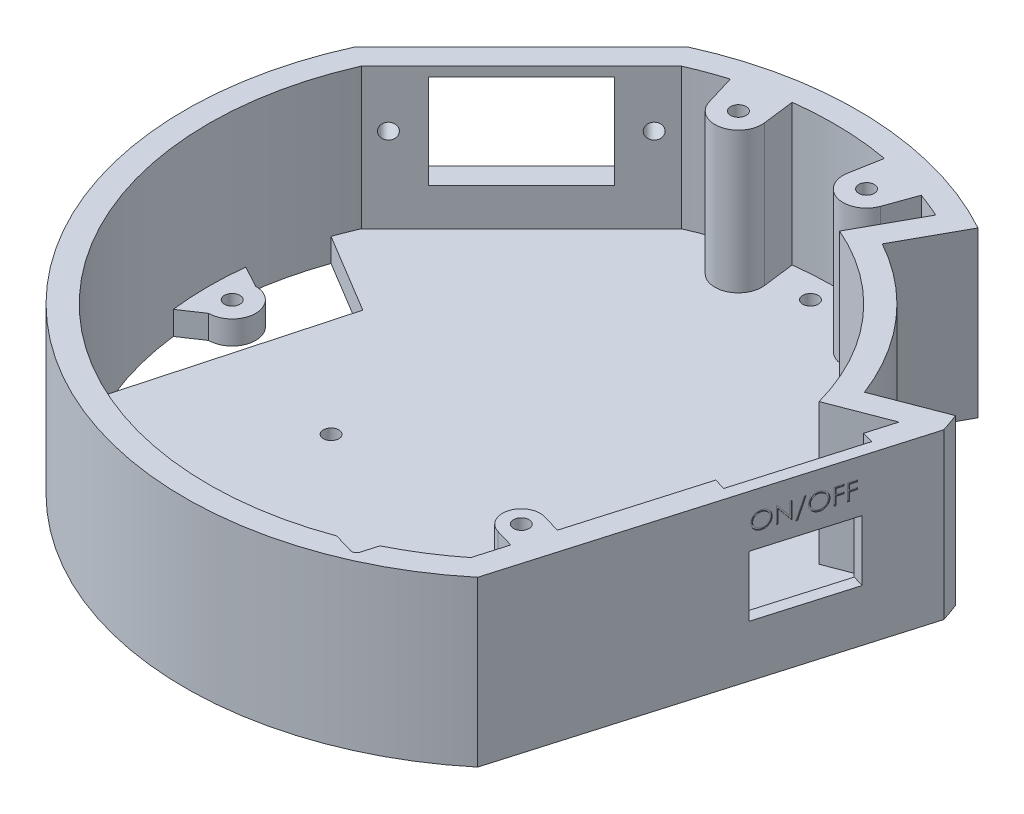
from build123d import *

# Parameters (mm, degrees)
BOSS_EXTRUDE1_DEPTH = 5
SKETCH2_R           = 1.65
CUT_EXTRUDE1_DEPTH  = 6
BOSS_EXTRUDE3_DEPTH = 30
CUT_EXTRUDE2_DEPTH  = 15
FILLET1_R           = 1
SKETCH5_R           = 1.65
CUT_EXTRUDE3_DEPTH  = 6
SKETCH6_R           = 1.65
SKETCH6_W           = 28
SKETCH6_H           = 20
CUT_EXTRUDE4_DEPTH  = 102.17990932
SKETCH7_W           = 19.4
SKETCH7_H           = 12.9
CUT_EXTRUDE5_DEPTH  = 5
CUT_EXTRUDE6_START  = -2.5
SKETCH8_W           = 25.4
SKETCH8_H           = 30
CUT_EXTRUDE6_DEPTH  = 5
CUT_EXTRUDE7_DEPTH  = 0.2
CUT_EXTRUDE8_DEPTH  = 6
SKETCH11_R          = 1.65
BOSS_EXTRUDE4_DEPTH = 35
CUT_EXTRUDE9_START  = -3
CUT_EXTRUDE9_DEPTH  = 2.6


with BuildPart() as part:
    # Sketch1 → Boss-Extrude1 (new body)
    with BuildSketch(Plane(origin=(0, 0, 0), x_dir=(1, 0, 0), z_dir=(0, 1, 0))):
        with BuildLine():
            Line((45.736375855, -55.017005995), (68.149505263, 21.779163377))
            ThreePointArc((68.149505263, 21.779163377), (67.498860282, 23.71899841), (66.793011614, 25.63943495))
            Line((66.793011614, 25.63943495), (52.789305216, 20.263915707))
            ThreePointArc((52.789305216, 20.263915707), (42.645904251, 37.130363258), (27.335841873, 49.498371429))
            Line((27.335841873, 49.498371429), (34.587369472, 62.629073903))
            ThreePointArc((34.587369472, 62.629073903), (2.723048346, 71.493160741), (-29.723211396, 65.078550455))
            Line((-29.723211396, 65.078550455), (-65.078550455, 29.723211396))
            ThreePointArc((-65.078550455, 29.723211396), (-43.459820989, -56.832481774), (45.736375855, -55.017005995))
        make_face()
    extrude(amount=BOSS_EXTRUDE1_DEPTH)

    # Sketch2 → Cut-Extrude1 (cut, through all)
    with BuildSketch(Plane(origin=(0, 5, 0), x_dir=(1, 0, 0), z_dir=(0, 1, 0))):
        with Locations((0, 61.55)):
            Circle(SKETCH2_R)
        with Locations((-43.522422382, -43.522422382)):
            Circle(SKETCH2_R)
        with Locations((-61.55, 0)):
            Circle(SKETCH2_R)
        with Locations((3.221278107, -61.465647864)):
            Circle(SKETCH2_R)
    extrude(amount=-CUT_EXTRUDE1_DEPTH, mode=Mode.SUBTRACT)

    # Sketch3 → Boss-Extrude3 (add)
    with BuildSketch(Plane(origin=(0, 5, 0), x_dir=(1, 0, 0), z_dir=(0, 1, 0))):
        with BuildLine():
            Line((34.587369472, 62.629073903), (27.335841873, 49.498371429))
            ThreePointArc((27.335841873, 49.498371429), (42.645904251, 37.130363258), (52.789305216, 20.263915707))
            Line((52.789305216, 20.263915707), (66.793011614, 25.63943495))
            ThreePointArc((66.793011614, 25.63943495), (67.498860282, 23.71899841), (68.149505263, 21.779163377))
            Line((68.149505263, 21.779163377), (45.736375855, -55.017005995))
            ThreePointArc((45.736375855, -55.017005995), (-43.459820989, -56.832481774), (-65.078550455, 29.723211396))
            Line((-65.078550455, 29.723211396), (-29.723211396, 65.078550455))
            ThreePointArc((-29.723211396, 65.078550455), (2.723048346, 71.493160741), (34.587369472, 62.629073903))
        make_face()
        with BuildLine():
            Line((41.373300987, -52.119928918), (61.963390881, 18.42979228))
            Line((61.963390881, 18.42979228), (49.686308368, 13.717061848))
            ThreePointArc((49.686308368, 13.717061848), (38.874933851, 33.847105387), (20.424251898, 47.32585931))
            Line((20.424251898, 47.32585931), (27.702354426, 60.504682333))
            ThreePointArc((27.702354426, 60.504682333), (0.474099558, 66.543311118), (-26.837433367, 60.893260672))
            Line((-26.837433367, 60.893260672), (-60.893260672, 26.837433367))
            ThreePointArc((-60.893260672, 26.837433367), (-40.667228468, -52.672702168), (41.373300987, -52.119928918))
        make_face(mode=Mode.SUBTRACT)
    extrude(amount=BOSS_EXTRUDE3_DEPTH)

    # Sketch4 → Cut-Extrude2 (cut)
    with BuildSketch(Plane(origin=(-10.769878987, 0, 36.901828197), x_dir=(0, -1, 0), z_dir=(0.280164118, 0, -0.959952117))):
        with BuildLine():
            Line((-19, -45.06852177), (-35, -45.06852177))
            ThreePointArc((-35, -45.06852177), (-38.5, -41.56852177), (-35, -38.06852177))
            Line((-35, -38.06852177), (-19, -38.06852177))
            ThreePointArc((-19, -38.06852177), (-15.5, -41.56852177), (-19, -45.06852177))
        make_face()
    extrude(amount=-CUT_EXTRUDE2_DEPTH, mode=Mode.SUBTRACT)

    # Fillet1
    fillet1_edges = [part.edges().sort_by_distance(p)[0] for p in [
        (26.529321315, 15.921147738, 63.413460481),
        (28.291282139, 27, 63.927692588),
    ]]
    fillet(fillet1_edges, radius=FILLET1_R)

    # Sketch5 → Cut-Extrude3 (cut, through all)
    with BuildSketch(Plane(origin=(0, 5, 0), x_dir=(1, 0, 0), z_dir=(0, 1, 0))):
        with Locations((26.569138232, -29.673397669)):
            Circle(SKETCH5_R)
        with Locations((-26.228228211, -14.264371202)):
            Circle(SKETCH5_R)
    extrude(amount=-CUT_EXTRUDE3_DEPTH, mode=Mode.SUBTRACT)

    # Sketch6 → Cut-Extrude4 (cut, through all)
    with BuildSketch(Plane(origin=(0, 0, 0), x_dir=(0.707106781, 0, -0.707106781), z_dir=(0.707106781, 0, 0.707106781))):
        with Locations((20, 23)):
            Circle(SKETCH6_R)
        with Locations((-20, 23)):
            Circle(SKETCH6_R)
        with Locations((0, 23)):
            Rectangle(SKETCH6_W, SKETCH6_H)
    extrude(amount=-CUT_EXTRUDE4_DEPTH, mode=Mode.SUBTRACT)

    # Sketch7 → Cut-Extrude5 (cut)
    with BuildSketch(Plane(origin=(56.942940559, 0, 16.618921309), x_dir=(0.280164118, 0, -0.959952117), z_dir=(0.959952117, 0, 0.280164118))):
        with Locations((16.3, 17.5)):
            Rectangle(SKETCH7_W, SKETCH7_H)
    extrude(amount=-CUT_EXTRUDE5_DEPTH, mode=Mode.SUBTRACT)

    # Sketch8 → Cut-Extrude6 (cut)
    with BuildSketch(Plane(origin=(56.942940559, 0, 16.618921309), x_dir=(0.280164118, 0, -0.959952117), z_dir=(0.959952117, 0, 0.280164118)).offset(CUT_EXTRUDE6_START)):
        with Locations((16.3, 20)):
            Rectangle(SKETCH8_W, SKETCH8_H)
    extrude(amount=-CUT_EXTRUDE6_DEPTH, mode=Mode.SUBTRACT)

    # Sketch9 → Cut-Extrude7 (cut)
    with BuildSketch(Plane(origin=(56.942940559, 0, 16.618921309), x_dir=(0.280164118, 0, -0.959952117), z_dir=(0.959952117, 0, 0.280164118))):
        with BuildLine():
            add(Edge.make_bspline(
                [(8.682970513, 30.909861948), (8.747778619, 30.908220468), (8.875067086, 30.904996468), (9.062141983, 30.880317364), (9.240737079, 30.837621974), (9.412307218, 30.780758992), (9.574800194, 30.704904606), (9.729439087, 30.613219458), (9.87585596, 30.504742999), (10.012077342, 30.380313772), (10.136734292, 30.244930318), (10.246560179, 30.100452408), (10.338602472, 29.947753606), (10.414188259, 29.787292775), (10.473486869, 29.619432807), (10.514405913, 29.443278805), (10.540544063, 29.259972114), (10.54359984, 29.13494525), (10.54515, 29.071520602)],
                knots=[0, 0, 0, 0, 0.000194393, 0.000381804, 0.00056479, 0.000744601, 0.000923091, 0.001101652, 0.001283106, 0.001468738, 0.001654324, 0.001834514, 0.002012231, 0.002188181, 0.002365797, 0.002545211, 0.002729936, 0.002920126, 0.002920126, 0.002920126, 0.002920126], degree=3))
            add(Edge.make_bspline(
                [(10.54515, 29.071520602), (10.543600068, 29.008563155), (10.540544971, 28.884466735), (10.514376193, 28.702323291), (10.473335193, 28.527232594), (10.414738927, 28.359486941), (10.339513449, 28.198909378), (10.246858278, 28.045922424), (10.137717067, 27.900475925), (10.013510216, 27.76416326), (9.878109174, 27.63916579), (9.732878907, 27.530246914), (9.581085587, 27.436522789), (9.420775879, 27.361739115), (9.254075842, 27.301967195), (9.079493519, 27.261214565), (8.897846965, 27.234927522), (8.773975961, 27.231909006), (8.711015385, 27.230374768)],
                knots=[0, 0, 0, 0, 0.000188789, 0.000372126, 0.000550857, 0.00072758, 0.000904164, 0.001081881, 0.001263191, 0.001448823, 0.00163441, 0.001815159, 0.001992641, 0.002168591, 0.002344885, 0.002522934, 0.002705576, 0.002894365, 0.002894365, 0.002894365, 0.002894365], degree=3))
            add(Edge.make_bspline(
                [(8.711015385, 27.230374768), (8.647591066, 27.231924155), (8.52256485, 27.234978409), (8.339027814, 27.261159814), (8.162750071, 27.302101118), (7.994235719, 27.360610554), (7.83339079, 27.436227785), (7.679900707, 27.528432164), (7.53438156, 27.637839305), (7.398039813, 27.762005879), (7.273290615, 27.897177432), (7.164531239, 28.042011687), (7.072306126, 28.193667143), (6.996942794, 28.352564667), (6.937278334, 28.51793611), (6.896573516, 28.690884588), (6.870237564, 28.870424093), (6.867202718, 28.992666992), (6.865662821, 29.054693679)],
                knots=[0, 0, 0, 0, 0.00019019, 0.000374915, 0.000555011, 0.000732396, 0.00090898, 0.001087298, 0.001268608, 0.00145424, 0.001639827, 0.001819595, 0.001996712, 0.002171394, 0.002346367, 0.002523053, 0.002703612, 0.002889599, 0.002889599, 0.002889599, 0.002889599], degree=3))
            add(Edge.make_bspline(
                [(6.865662821, 29.054693679), (6.866197456, 29.096326348), (6.867259982, 29.179066471), (6.880051675, 29.301933071), (6.898613376, 29.422823729), (6.925215289, 29.541394677), (6.960006956, 29.657355662), (7.001058983, 29.771506425), (7.051198828, 29.882690148), (7.107879476, 29.99143354), (7.171141284, 30.096041446), (7.241017034, 30.194921029), (7.315052402, 30.288902026), (7.396215796, 30.37554903), (7.481832241, 30.457382686), (7.573290619, 30.533145403), (7.670032864, 30.603520354), (7.772475243, 30.666940695), (7.878093518, 30.72429983), (7.986970296, 30.773521681), (8.097626868, 30.815767742), (8.210581516, 30.850008567), (8.325534288, 30.877040603), (8.442736072, 30.895447957), (8.562093498, 30.908272275), (8.642504817, 30.909329777), (8.682970513, 30.909861948)],
                knots=[0, 0, 0, 0, 0.000124849, 0.000248123, 0.000370193, 0.00049164, 0.000612319, 0.000733199, 0.000855287, 0.000977905, 0.001100913, 0.001221706, 0.001340948, 0.001459521, 0.001577551, 0.001696047, 0.001815534, 0.001936153, 0.002057243, 0.002175846, 0.002294342, 0.002412335, 0.002529682, 0.00264829, 0.002768075, 0.00288942, 0.00288942, 0.00288942, 0.00288942], degree=3))
        make_face()
        with BuildLine():
            add(Edge.make_bspline(
                [(8.698395192, 30.550887589), (8.665180559, 30.550482699), (8.599068826, 30.549676789), (8.50078429, 30.539061073), (8.403792356, 30.523931184), (8.308072994, 30.502349664), (8.214026704, 30.472945611), (8.120776863, 30.439104703), (8.029173809, 30.397883612), (7.939519951, 30.351310908), (7.852604876, 30.299761987), (7.770592175, 30.24279022), (7.693269531, 30.181731666), (7.620826264, 30.116443828), (7.553475092, 30.046594226), (7.489890391, 29.97324179), (7.432620809, 29.894289899), (7.380135232, 29.811879492), (7.333167392, 29.726117911), (7.291402037, 29.637908049), (7.257238028, 29.546530362), (7.229375652, 29.452976205), (7.206275841, 29.357393745), (7.191641917, 29.259057896), (7.180909558, 29.158462784), (7.180149712, 29.09048093), (7.179765385, 29.056095922)],
                knots=[0, 0, 0, 0, 9.9599e-05, 0.000198245, 0.000296222, 0.00039402, 0.00049227, 0.000591646, 0.000691452, 0.000793368, 0.000894612, 0.000994383, 0.001092713, 0.00119001, 0.001286696, 0.001383657, 0.001480979, 0.001579008, 0.001676595, 0.001774142, 0.001871547, 0.001968922, 0.002066879, 0.00216624, 0.00226698, 0.002370083, 0.002370083, 0.002370083, 0.002370083], degree=3))
            add(Edge.make_bspline(
                [(7.179765385, 29.056095922), (7.181040247, 29.005533701), (7.183548295, 28.906062171), (7.205505865, 28.760294027), (7.239327839, 28.620205741), (7.289185206, 28.486563832), (7.35153582, 28.358219549), (7.42856271, 28.236311444), (7.519821796, 28.12080657), (7.623485323, 28.012511301), (7.736808029, 27.913665497), (7.857140759, 27.826902088), (7.983194367, 27.753491838), (8.115297569, 27.693686766), (8.252745108, 27.646297028), (8.396422659, 27.613818397), (8.545373119, 27.592442941), (8.646903774, 27.590390185), (8.698395192, 27.589349127)],
                knots=[0, 0, 0, 0, 0.000151605, 0.000298253, 0.000441263, 0.000583229, 0.000725274, 0.000868635, 0.001014928, 0.001166177, 0.001317744, 0.00146543, 0.001610576, 0.001754594, 0.001899821, 0.002045914, 0.002195936, 0.002350312, 0.002350312, 0.002350312, 0.002350312], degree=3))
            add(Edge.make_bspline(
                [(8.698395192, 27.589349127), (8.733004694, 27.589824632), (8.80164573, 27.5907677), (8.903741253, 27.600266376), (9.003997464, 27.615498246), (9.102273744, 27.637428902), (9.198458556, 27.664876108), (9.292953359, 27.697483836), (9.384751649, 27.73816504), (9.475011487, 27.783112991), (9.561407729, 27.834353149), (9.643883261, 27.889391298), (9.720359241, 27.950359919), (9.792748312, 28.014677732), (9.860376001, 28.083641579), (9.922784985, 28.157161801), (9.979765118, 28.235702459), (10.032230764, 28.317987864), (10.079034027, 28.403984117), (10.119813126, 28.492513795), (10.154409242, 28.583358904), (10.182337747, 28.676650476), (10.204223208, 28.772211325), (10.219303128, 28.870169403), (10.229851567, 28.970328745), (10.230646644, 29.038072601), (10.231047436, 29.072221723)],
                knots=[0, 0, 0, 0, 0.000103804, 0.000205874, 0.000307314, 0.000407849, 0.000507719, 0.000607281, 0.000707445, 0.000808723, 0.000909609, 0.001008589, 0.001105934, 0.001202762, 0.001298946, 0.001395452, 0.001491794, 0.001589823, 0.001688026, 0.001785277, 0.001882027, 0.001979402, 0.0020772, 0.002175869, 0.002276609, 0.002379011, 0.002379011, 0.002379011, 0.002379011], degree=3))
            add(Edge.make_bspline(
                [(10.231047436, 29.072221723), (10.230646323, 29.106137228), (10.229850642, 29.173414878), (10.219308167, 29.272875696), (10.204207277, 29.370128908), (10.182444568, 29.464792711), (10.154394415, 29.556891236), (10.119807084, 29.646337984), (10.079021785, 29.733466179), (10.032213561, 29.818060476), (9.979597737, 29.899235214), (9.922103494, 29.976837626), (9.858738146, 30.049410367), (9.791312121, 30.118745061), (9.718141235, 30.183362951), (9.639556941, 30.243285472), (9.556513264, 30.299958746), (9.468586028, 30.351084308), (9.377842074, 30.398298541), (9.284728116, 30.438749544), (9.190299017, 30.473121663), (9.094794904, 30.502438628), (8.997411926, 30.523846658), (8.898808097, 30.539074708), (8.799119839, 30.549673094), (8.732076619, 30.550481473), (8.698395192, 30.550887589)],
                knots=[0, 0, 0, 0, 0.000101701, 0.000201743, 0.00029972, 0.000396835, 0.000492868, 0.000588308, 0.000684288, 0.000781261, 0.000878109, 0.000974304, 0.001070733, 0.001166917, 0.001264269, 0.001363274, 0.001463228, 0.001565678, 0.001668217, 0.001769947, 0.001869982, 0.001969573, 0.002069423, 0.002168785, 0.002268827, 0.002369827, 0.002369827, 0.002369827, 0.002369827], degree=3))
        make_face(mode=Mode.SUBTRACT)
        Polygon((11.263098718, 27.320118358), (11.263098718, 30.820118358), (11.329004167, 30.820118358), (13.641303846, 28.065410826), (13.641303846, 30.820118358), (13.95540641, 30.820118358), (13.95540641, 27.320118358), (13.883891987, 27.320118358), (11.577201282, 30.068515794), (11.577201282, 27.320118358), align=None)
        Polygon((16.378483333, 30.909861948), (14.914541026, 26.826528614), (14.583611539, 26.826528614), (16.047553846, 30.909861948), align=None)
        with BuildLine():
            add(Edge.make_bspline(
                [(18.59963718, 30.909861948), (18.664445285, 30.908220468), (18.791733752, 30.904996468), (18.97880865, 30.880317364), (19.157403745, 30.837621974), (19.328973884, 30.780758992), (19.491466861, 30.704904606), (19.646105753, 30.613219458), (19.792522627, 30.504742999), (19.928744009, 30.380313772), (20.053400959, 30.244930318), (20.163226845, 30.100452408), (20.255269139, 29.947753606), (20.330854926, 29.787292775), (20.390153536, 29.619432807), (20.431072579, 29.443278805), (20.45721073, 29.259972114), (20.460266507, 29.13494525), (20.461816667, 29.071520602)],
                knots=[0, 0, 0, 0, 0.000194393, 0.000381804, 0.00056479, 0.000744601, 0.000923091, 0.001101652, 0.001283106, 0.001468738, 0.001654324, 0.001834514, 0.002012231, 0.002188181, 0.002365797, 0.002545211, 0.002729936, 0.002920126, 0.002920126, 0.002920126, 0.002920126], degree=3))
            add(Edge.make_bspline(
                [(20.461816667, 29.071520602), (20.460266734, 29.008563155), (20.457211638, 28.884466735), (20.43104286, 28.702323291), (20.39000186, 28.527232594), (20.331405594, 28.359486941), (20.256180116, 28.198909378), (20.163524944, 28.045922424), (20.054383734, 27.900475925), (19.930176883, 27.76416326), (19.794775841, 27.63916579), (19.649545574, 27.530246914), (19.497752254, 27.436522789), (19.337442546, 27.361739115), (19.170742509, 27.301967195), (18.996160186, 27.261214565), (18.814513632, 27.234927522), (18.690642628, 27.231909006), (18.627682051, 27.230374768)],
                knots=[0, 0, 0, 0, 0.000188789, 0.000372126, 0.000550857, 0.00072758, 0.000904164, 0.001081881, 0.001263191, 0.001448823, 0.00163441, 0.001815159, 0.001992641, 0.002168591, 0.002344885, 0.002522934, 0.002705576, 0.002894365, 0.002894365, 0.002894365, 0.002894365], degree=3))
            add(Edge.make_bspline(
                [(18.627682051, 27.230374768), (18.564257732, 27.231924155), (18.439231516, 27.234978409), (18.255694481, 27.261159814), (18.079416737, 27.302101118), (17.910902386, 27.360610554), (17.750057456, 27.436227785), (17.596567374, 27.528432164), (17.451048226, 27.637839305), (17.31470648, 27.762005879), (17.189957282, 27.897177432), (17.081197906, 28.042011687), (16.988972793, 28.193667143), (16.91360946, 28.352564667), (16.853945001, 28.51793611), (16.813240183, 28.690884588), (16.786904231, 28.870424093), (16.783869384, 28.992666992), (16.782329487, 29.054693679)],
                knots=[0, 0, 0, 0, 0.00019019, 0.000374915, 0.000555011, 0.000732396, 0.00090898, 0.001087298, 0.001268608, 0.00145424, 0.001639827, 0.001819595, 0.001996712, 0.002171394, 0.002346367, 0.002523053, 0.002703612, 0.002889599, 0.002889599, 0.002889599, 0.002889599], degree=3))
            add(Edge.make_bspline(
                [(16.782329487, 29.054693679), (16.782864123, 29.096326348), (16.783926649, 29.179066471), (16.796718342, 29.301933071), (16.815280043, 29.422823729), (16.841881955, 29.541394677), (16.876673622, 29.657355662), (16.91772565, 29.771506425), (16.967865495, 29.882690148), (17.024546143, 29.99143354), (17.087807951, 30.096041446), (17.157683701, 30.194921029), (17.231719069, 30.288902026), (17.312882463, 30.37554903), (17.398498908, 30.457382686), (17.489957286, 30.533145403), (17.58669953, 30.603520354), (17.68914191, 30.666940695), (17.794760185, 30.72429983), (17.903636963, 30.773521681), (18.014293534, 30.815767742), (18.127248182, 30.850008567), (18.242200954, 30.877040603), (18.359402739, 30.895447957), (18.478760165, 30.908272275), (18.559171484, 30.909329777), (18.59963718, 30.909861948)],
                knots=[0, 0, 0, 0, 0.000124849, 0.000248123, 0.000370193, 0.00049164, 0.000612319, 0.000733199, 0.000855287, 0.000977905, 0.001100913, 0.001221706, 0.001340948, 0.001459521, 0.001577551, 0.001696047, 0.001815534, 0.001936153, 0.002057243, 0.002175846, 0.002294342, 0.002412335, 0.002529682, 0.00264829, 0.002768075, 0.00288942, 0.00288942, 0.00288942, 0.00288942], degree=3))
        make_face()
        with BuildLine():
            add(Edge.make_bspline(
                [(18.615061859, 30.550887589), (18.581847226, 30.550482699), (18.515735493, 30.549676789), (18.417450956, 30.539061073), (18.320459023, 30.523931184), (18.22473966, 30.502349664), (18.130693371, 30.472945611), (18.03744353, 30.439104703), (17.945840476, 30.397883612), (17.856186618, 30.351310908), (17.769271543, 30.299761987), (17.687258841, 30.24279022), (17.609936197, 30.181731666), (17.537492931, 30.116443828), (17.470141759, 30.046594226), (17.406557057, 29.97324179), (17.349287476, 29.894289899), (17.296801899, 29.811879492), (17.249834058, 29.726117911), (17.208068704, 29.637908049), (17.173904695, 29.546530362), (17.146042319, 29.452976205), (17.122942508, 29.357393745), (17.108308584, 29.259057896), (17.097576224, 29.158462784), (17.096816379, 29.09048093), (17.096432051, 29.056095922)],
                knots=[0, 0, 0, 0, 9.9599e-05, 0.000198245, 0.000296222, 0.00039402, 0.00049227, 0.000591646, 0.000691452, 0.000793368, 0.000894612, 0.000994383, 0.001092713, 0.00119001, 0.001286696, 0.001383657, 0.001480979, 0.001579008, 0.001676595, 0.001774142, 0.001871547, 0.001968922, 0.002066879, 0.00216624, 0.00226698, 0.002370083, 0.002370083, 0.002370083, 0.002370083], degree=3))
            add(Edge.make_bspline(
                [(17.096432051, 29.056095922), (17.097706913, 29.005533701), (17.100214961, 28.906062171), (17.122172531, 28.760294027), (17.155994506, 28.620205741), (17.205851872, 28.486563832), (17.268202487, 28.358219549), (17.345229377, 28.236311444), (17.436488463, 28.12080657), (17.540151989, 28.012511301), (17.653474696, 27.913665497), (17.773807426, 27.826902088), (17.899861033, 27.753491838), (18.031964236, 27.693686766), (18.169411775, 27.646297028), (18.313089326, 27.613818397), (18.462039786, 27.592442941), (18.563570441, 27.590390185), (18.615061859, 27.589349127)],
                knots=[0, 0, 0, 0, 0.000151605, 0.000298253, 0.000441263, 0.000583229, 0.000725274, 0.000868635, 0.001014928, 0.001166177, 0.001317744, 0.00146543, 0.001610576, 0.001754594, 0.001899821, 0.002045914, 0.002195936, 0.002350312, 0.002350312, 0.002350312, 0.002350312], degree=3))
            add(Edge.make_bspline(
                [(18.615061859, 27.589349127), (18.649671361, 27.589824632), (18.718312397, 27.5907677), (18.820407919, 27.600266376), (18.920664131, 27.615498246), (19.018940411, 27.637428902), (19.115125222, 27.664876108), (19.209620026, 27.697483836), (19.301418316, 27.73816504), (19.391678154, 27.783112991), (19.478074395, 27.834353149), (19.560549928, 27.889391298), (19.637025907, 27.950359919), (19.709414979, 28.014677732), (19.777042668, 28.083641579), (19.839451652, 28.157161801), (19.896431784, 28.235702459), (19.948897431, 28.317987864), (19.995700694, 28.403984117), (20.036479793, 28.492513795), (20.071075909, 28.583358904), (20.099004413, 28.676650476), (20.120889875, 28.772211325), (20.135969795, 28.870169403), (20.146518234, 28.970328745), (20.147313311, 29.038072601), (20.147714103, 29.072221723)],
                knots=[0, 0, 0, 0, 0.000103804, 0.000205874, 0.000307314, 0.000407849, 0.000507719, 0.000607281, 0.000707445, 0.000808723, 0.000909609, 0.001008589, 0.001105934, 0.001202762, 0.001298946, 0.001395452, 0.001491794, 0.001589823, 0.001688026, 0.001785277, 0.001882027, 0.001979402, 0.0020772, 0.002175869, 0.002276609, 0.002379011, 0.002379011, 0.002379011, 0.002379011], degree=3))
            add(Edge.make_bspline(
                [(20.147714103, 29.072221723), (20.14731299, 29.106137228), (20.146517308, 29.173414878), (20.135974834, 29.272875696), (20.120873943, 29.370128908), (20.099111235, 29.464792711), (20.071061081, 29.556891236), (20.036473751, 29.646337984), (19.995688452, 29.733466179), (19.948880227, 29.818060476), (19.896264404, 29.899235214), (19.83877016, 29.976837626), (19.775404812, 30.049410367), (19.707978787, 30.118745061), (19.634807902, 30.183362951), (19.556223608, 30.243285472), (19.47317993, 30.299958746), (19.385252695, 30.351084308), (19.294508741, 30.398298541), (19.201394783, 30.438749544), (19.106965683, 30.473121663), (19.011461571, 30.502438628), (18.914078593, 30.523846658), (18.815474764, 30.539074708), (18.715786505, 30.549673094), (18.648743286, 30.550481473), (18.615061859, 30.550887589)],
                knots=[0, 0, 0, 0, 0.000101701, 0.000201743, 0.00029972, 0.000396835, 0.000492868, 0.000588308, 0.000684288, 0.000781261, 0.000878109, 0.000974304, 0.001070733, 0.001166917, 0.001264269, 0.001363274, 0.001463228, 0.001565678, 0.001668217, 0.001769947, 0.001869982, 0.001969573, 0.002069423, 0.002168785, 0.002268827, 0.002369827, 0.002369827, 0.002369827, 0.002369827], degree=3))
        make_face(mode=Mode.SUBTRACT)
        Polygon((21.179765385, 30.820118358), (22.88489359, 30.820118358), (22.88489359, 30.461143999), (21.493867949, 30.461143999), (21.493867949, 29.384220922), (22.88489359, 29.384220922), (22.88489359, 29.025246563), (21.493867949, 29.025246563), (21.493867949, 27.320118358), (21.179765385, 27.320118358), align=None)
        Polygon((23.513098718, 30.820118358), (25.218226923, 30.820118358), (25.218226923, 30.461143999), (23.827201282, 30.461143999), (23.827201282, 29.384220922), (25.218226923, 29.384220922), (25.218226923, 29.025246563), (23.827201282, 29.025246563), (23.827201282, 27.320118358), (23.513098718, 27.320118358), align=None)
    extrude(amount=-CUT_EXTRUDE7_DEPTH, mode=Mode.SUBTRACT)

    # Sketch10 → Cut-Extrude8 (cut)
    with BuildSketch(Plane(origin=(0, 0, 0), x_dir=(1, 0, 0), z_dir=(0, 1, 0))):
        with BuildLine():
            Line((-61.55, -5), (-66.059328559, -8.025094099))
            ThreePointArc((-66.059328559, -8.025094099), (-63.224651437, -20.75766065), (-57.960586534, -32.692620477))
            Line((-57.960586534, -32.692620477), (-45.744307294, 12.001168416))
            Line((-45.744307294, 12.001168416), (-62.726398584, 22.217919473))
            ThreePointArc((-62.726398584, 22.217919473), (-64.844935264, 14.945614596), (-66.123306155, 7.479666314))
            Line((-66.123306155, 7.479666314), (-61.55, 5))
            ThreePointArc((-61.55, 5), (-56.55, 0), (-61.55, -5))
        make_face()
    extrude(amount=CUT_EXTRUDE8_DEPTH, mode=Mode.SUBTRACT)

    # Sketch11 → Boss-Extrude4 (add)
    with BuildSketch(Plane(origin=(0, 0, 0), x_dir=(1, 0, 0), z_dir=(0, 1, 0))):
        with BuildLine():
            Line((20.234131808, 56.263486472), (22.519667869, 62.618699955))
            ThreePointArc((22.519667869, 62.618699955), (17.223113356, 64.27753411), (11.806745518, 65.489218848))
            Line((11.806745518, 65.489218848), (10.608471067, 58.842674494))
            ThreePointArc((10.608471067, 58.842674494), (14.235047481, 53.125920446), (20.234131808, 56.263486472))
        make_face()
        with Locations((15.529142706, 57.955549577)):
            Circle(SKETCH11_R, mode=Mode.SUBTRACT)
        with BuildLine():
            Line((41.696306043, -36.735841104), (45.536114512, -37.856497574))
            Line((45.536114512, -37.856497574), (43.294801571, -45.536114512))
            Line((43.294801571, -45.536114512), (39.454993102, -44.415458041))
            ThreePointArc((39.454993102, -44.415458041), (36.735841104, -39.454993102), (41.696306043, -36.735841104))
        make_face()
        with Locations((40.575649573, -40.575649573)):
            Circle(SKETCH11_R, mode=Mode.SUBTRACT)
        with BuildLine():
            Line((-17.261798267, 57.245351956), (-19.211595906, 63.711471555))
            ThreePointArc((-19.211595906, 63.711471555), (-13.835483465, 65.090832091), (-8.363123891, 66.017385466))
            Line((-8.363123891, 66.017385466), (-7.514344888, 59.317237131))
            ThreePointArc((-7.514344888, 59.317237131), (-11.435142995, 53.79811804), (-17.261798267, 57.245351956))
        make_face()
        with Locations((-12.474701449, 58.688856044)):
            Circle(SKETCH11_R, mode=Mode.SUBTRACT)
    extrude(amount=BOSS_EXTRUDE4_DEPTH)

    # Sketch12 → Cut-Extrude9 (cut)
    with BuildSketch(Plane(origin=(0, 35, 0), x_dir=(1, 0, 0), z_dir=(0, 1, 0)).offset(CUT_EXTRUDE9_START)):
        Polygon((18.704569187, 57.955549577), (17.116855946, 60.705549577), (13.941429466, 60.705549577), (12.353716226, 57.955549577), (13.941429466, 55.205549577), (17.116855946, 55.205549577), align=None)
        Polygon((-9.299274969, 58.688856044), (-10.886988209, 61.438856044), (-14.062414689, 61.438856044), (-15.65012793, 58.688856044), (-14.062414689, 55.938856044), (-10.886988209, 55.938856044), align=None)
        Polygon((43.751076053, -40.575649573), (42.163362813, -37.825649573), (38.987936332, -37.825649573), (37.400223092, -40.575649573), (38.987936332, -43.325649573), (42.163362813, -43.325649573), align=None)
    extrude(amount=-CUT_EXTRUDE9_DEPTH, mode=Mode.SUBTRACT)


solid = part.part
